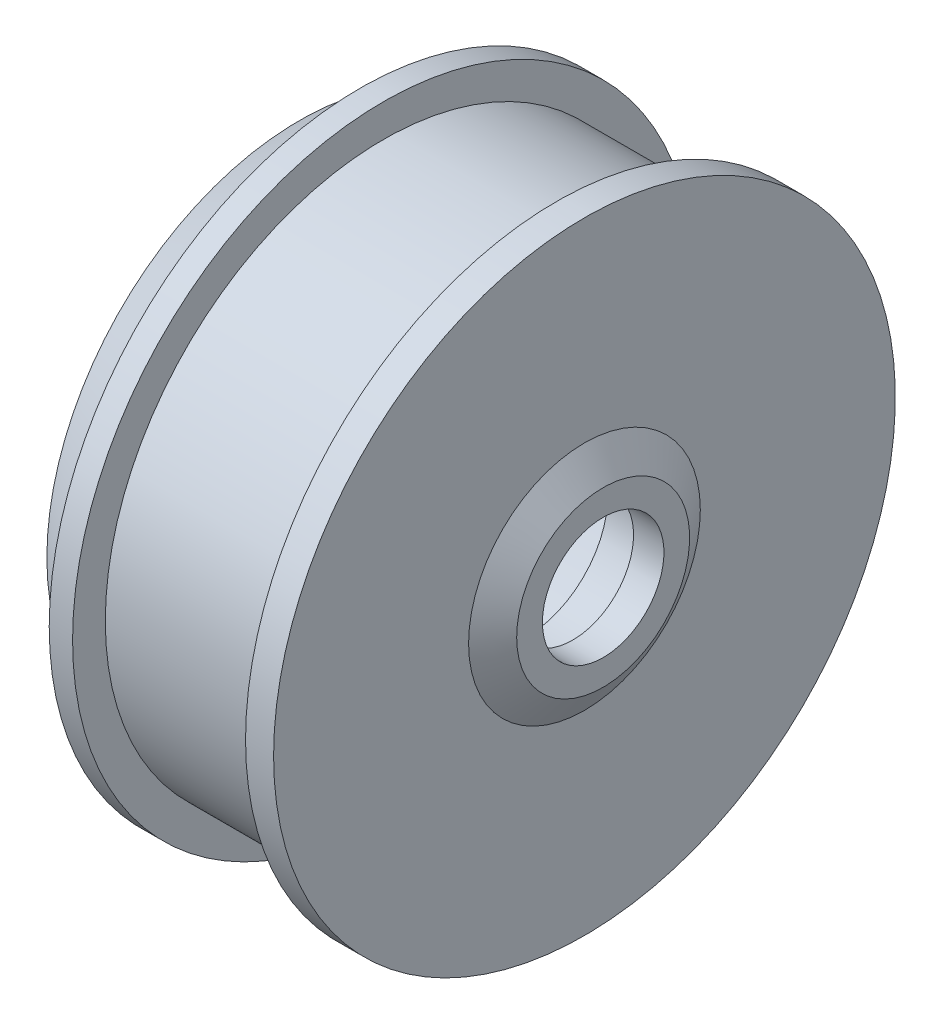
from build123d import *


with BuildPart() as part:
    # Sketch2 → Revolve1 (revolve)
    with BuildSketch(Plane.XY, mode=Mode.PRIVATE) as revolve1_sk:
        Polygon((-36, 0), (-36, 54), (-23, 63), (-23, 66.5), (-18, 66.5), (-18, 59.5), (19, 59.5), (19, 53), (-28, 53), (-28, 22.5), (-14.5, 22.5), (-14.5, 17.5), (-24.5, 17.5), (-24.5, 14.5), (-28, 14.5), (-28, 0), align=None)
    revolve(revolve1_sk.sketch.rotate(Axis((-84.605982482, 0, 0), (1, 0, 0)), 90), axis=Axis((-84.605982482, 0, 0), (1, 0, 0)))  # turned: the seam where the file's is


with BuildPart() as body_2:
    # Sketch2_3 → Revolve2 (revolve)
    with BuildSketch(Plane.XY, mode=Mode.PRIVATE) as revolve2_sk:
        Polygon((19, 66.5), (19, 59.5), (19, 53), (15.5, 53), (15.5, 50.5), (22.5, 50.5), (22.5, 22.5), (18, 22.5), (12.5, 19), (12.5, 17.5), (22.5, 17.5), (22.5, 13), (29, 13), (29, 18.5), (25, 24.785714286), (25, 66.5), align=None)
    revolve(revolve2_sk.sketch.rotate(Axis((-84.605982482, 0, 0), (1, 0, 0)), 90), axis=Axis((-84.605982482, 0, 0), (1, 0, 0)))  # turned: the seam where the file's is


solid = Compound([part.part, body_2.part])
